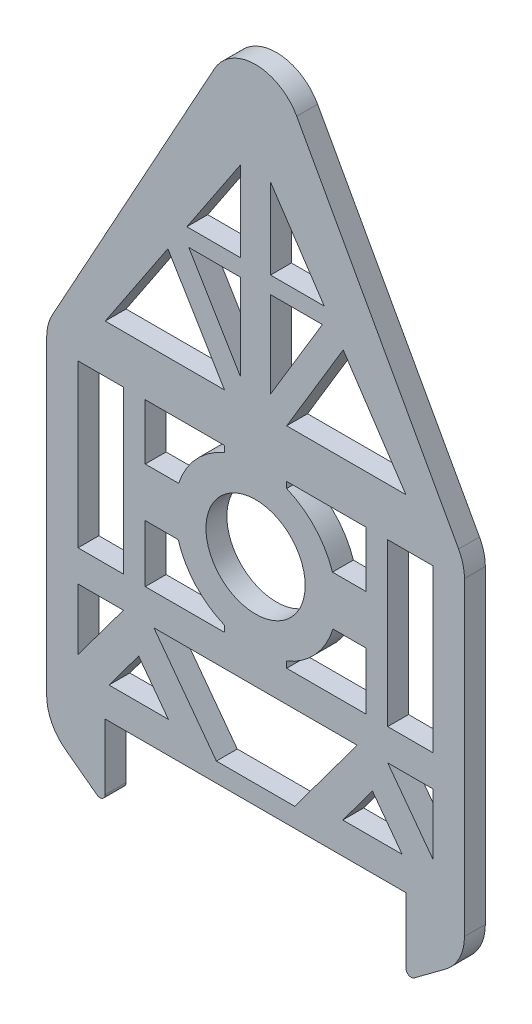
from build123d import *

# Parameters (mm, degrees)
SKETCH1_R           = 47.5
BOSS_EXTRUDE1_DEPTH = 20
FILLET1_R           = 45
FILLET2_R           = 5


with BuildPart() as part:
    # Sketch1 → Boss-Extrude1 (new body)
    with BuildSketch(Plane.XY):
        Polygon((-99.803538153, -268.977427834), (188.085436338, -268.977427834), (188.085436338, -341.607655446), (244.140949093, -299.966804473), (244.140949093, -268.977427834), (244.140949093, 31.022572166), (44.140949093, 393.998813233), (-155.859050907, 31.022572166), (-155.859050907, -268.977427834), (-155.859050907, -299.966804473), (-99.803538153, -341.607655446), align=None)
        with Locations((44.140949093, -62.521501175)):
            Circle(SKETCH1_R, mode=Mode.SUBTRACT)
        Polygon((-125.859050907, -170.021501175), (-82.349617269, -170.021501175), (-125.859050907, -228.592437053), align=None, mode=Mode.SUBTRACT)
        Polygon((6.643511339, -250.596190725), (-53.211415944, -170.021501175), (141.493314129, -170.021501175), (81.638386846, -250.596190725), align=None, mode=Mode.SUBTRACT)
        Polygon((184.483743739, -238.977427834), (127.641085844, -238.977427834), (156.062414792, -200.717590916), align=None, mode=Mode.SUBTRACT)
        Polygon((-125.859050907, -140.021501175), (-82.349617269, -140.021501175), (-82.349617269, -90.186397517), (-82.349617269, -47.519598178), (-82.349617269, 14.978498825), (-125.859050907, 14.978498825), (-125.859050907, -47.519598178), (-125.859050907, -90.186397517), align=None, mode=Mode.SUBTRACT)
        Polygon((29.800552112, 255.428707564), (-21.612263577, 178.30948403), (29.800552112, 178.30948403), align=None, mode=Mode.SUBTRACT)
        Polygon((188.085436338, 61.022572166), (128.063188969, 151.05594322), (73.913154487, 61.022572166), align=None, mode=Mode.SUBTRACT)
        Polygon((-99.803538153, 61.022572166), (14.368743698, 61.022572166), (-39.781290784, 151.05594322), align=None, mode=Mode.SUBTRACT)
        Polygon((214.140949093, -228.592437053), (170.631515454, -170.021501175), (214.140949093, -170.021501175), align=None, mode=Mode.SUBTRACT)
        Polygon((214.140949093, -140.021501175), (214.140949093, -90.186397517), (214.140949093, -47.519598178), (214.140949093, 14.978498825), (170.631515454, 14.978498825), (170.631515454, -47.519598178), (170.631515454, -90.186397517), (170.631515454, -140.021501175), align=None, mode=Mode.SUBTRACT)
        Polygon((-96.201845554, -238.977427834), (-39.359187659, -238.977427834), (-67.780516606, -200.717590916), align=None, mode=Mode.SUBTRACT)
        with BuildLine():
            Line((-61.485967642, 14.978498825), (-61.485967642, -38.366786979))
            Line((-61.485967642, -38.366786979), (-29.498712654, -38.366786979))
            ThreePointArc((-29.498712654, -38.366786979), (-12.737505242, -9.880343963), (14.368743698, 9.03173625))
            Line((14.368743698, 9.03173625), (14.368743698, 14.978498825))
            Line((14.368743698, 14.978498825), (-61.485967642, 14.978498825))
        make_face(mode=Mode.SUBTRACT)
        with BuildLine():
            Line((-61.485967642, -140.021501175), (-61.485967642, -85.255349829))
            Line((-61.485967642, -85.255349829), (-29.949685439, -85.255349829))
            ThreePointArc((-29.949685439, -85.255349829), (-13.241152292, -114.6131938), (14.368743698, -134.074738599))
            Line((14.368743698, -134.074738599), (14.368743698, -140.021501175))
            Line((14.368743698, -140.021501175), (-61.485967642, -140.021501175))
        make_face(mode=Mode.SUBTRACT)
        with BuildLine():
            Line((73.913154487, -134.074738599), (73.913154487, -140.021501175))
            Line((73.913154487, -140.021501175), (149.767865827, -140.021501175))
            Line((149.767865827, -140.021501175), (149.767865827, -85.255349829))
            Line((149.767865827, -85.255349829), (118.231583625, -85.255349829))
            ThreePointArc((118.231583625, -85.255349829), (101.523050478, -114.6131938), (73.913154487, -134.074738599))
        make_face(mode=Mode.SUBTRACT)
        with BuildLine():
            Line((73.913154487, 9.03173625), (73.913154487, 14.978498825))
            Line((73.913154487, 14.978498825), (149.767865827, 14.978498825))
            Line((149.767865827, 14.978498825), (149.767865827, -38.366786979))
            Line((149.767865827, -38.366786979), (117.780610839, -38.366786979))
            ThreePointArc((117.780610839, -38.366786979), (101.019403427, -9.880343963), (73.913154487, 9.03173625))
        make_face(mode=Mode.SUBTRACT)
        Polygon((108.124840655, 162.105125634), (58.481346073, 162.105125634), (58.481346073, 79.564621072), align=None, mode=Mode.SUBTRACT)
        Polygon((109.894161762, 178.30948403), (58.481346073, 255.428707564), (58.481346073, 178.30948403), align=None, mode=Mode.SUBTRACT)
        Polygon((-19.84294247, 162.105125634), (29.800552112, 79.564621072), (29.800552112, 162.105125634), align=None, mode=Mode.SUBTRACT)
    extrude(amount=BOSS_EXTRUDE1_DEPTH)

    # Fillet1
    fillet1_edges = [part.edges().sort_by_distance(p)[0] for p in [
        (244.140949093, -299.966804473, 10),
        (-155.859050907, -299.966804473, 10),
        (-155.859050907, 31.022572166, 10),
        (44.140949093, 393.998813233, 10),
        (244.140949093, 31.022572166, 10),
    ]]
    fillet(fillet1_edges, radius=FILLET1_R)

    # Fillet2
    fillet2_edges = [part.edges().sort_by_distance(p)[0] for p in [
        (188.085436338, -341.607655446, 10),
        (-99.803538153, -341.607655446, 10),
    ]]
    fillet(fillet2_edges, radius=FILLET2_R)


solid = part.part
